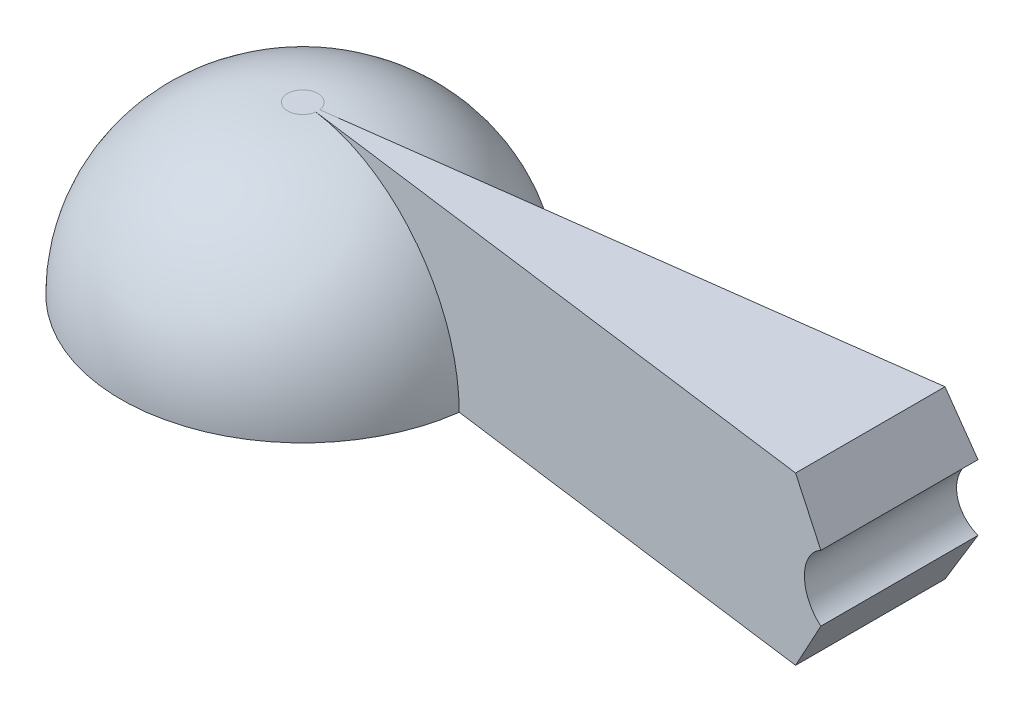
from build123d import *

# Parameters (mm, degrees)
REVOLVE2_ANGLE           = 7.5
REVOLVE2_OTHER_WAY_ANGLE = 7.5
CUT_EXTRUDE1_DEPTH       = 16.24
CUT_EXTRUDE1_DEPTH_BACK  = 16.24


with BuildPart() as part:
    # Sketch1 → Revolve1 (revolve)
    with BuildSketch(Plane.XY):
        with BuildLine():
            Line((0, 12.7), (-1.27, 12.7))
            Line((-1.27, 12.7), (-1.27, 13.97))
            Line((-1.27, 13.97), (0, 13.97))
            ThreePointArc((0, 13.97), (9.878281733, 9.878281733), (13.97, 0))
            Line((13.97, 0), (12.7, 0))
            ThreePointArc((12.7, 0), (8.980256121, 8.980256121), (0, 12.7))
        make_face()
    revolve(axis=Axis((-1.27, 13.97, 0), (0, -1, 0)))

    # Sketch3 → Revolve2 (revolve)
    with BuildSketch(Plane.XY):
        with BuildLine():
            Line((0, 13.97), (50.8, 13.97))
            Line((50.8, 13.97), (50.8, 0))
            Line((50.8, 0), (13.97, 0))
            ThreePointArc((13.97, 0), (9.878281733, 9.878281733), (0, 13.97))
        make_face()
    revolve(axis=Axis((-1.27, 13.97, 0), (0, -1, 0)), revolution_arc=REVOLVE2_ANGLE)

    # Sketch3 → Revolve2 other way (revolve)
    with BuildSketch(Plane.XY):
        with BuildLine():
            Line((0, 13.97), (50.8, 13.97))
            Line((50.8, 13.97), (50.8, 0))
            Line((50.8, 0), (13.97, 0))
            ThreePointArc((13.97, 0), (9.878281733, 9.878281733), (0, 13.97))
        make_face()
    revolve(axis=Axis((-1.27, 13.97, 0), (0, 1, 0)), revolution_arc=REVOLVE2_OTHER_WAY_ANGLE)

    # Sketch4 → Cut-Extrude1 (cut, two sides)
    with BuildSketch(Plane.XY) as cut_extrude1_sk:
        with BuildLine():
            Line((50.354533932, 13.97), (57.446880617, 13.97))
            Line((57.446880617, 13.97), (57.446880617, -0.511564319))
            Line((57.446880617, -0.511564319), (50.354533932, 0))
            Line((50.354533932, 0), (46.321742301, 0))
            Line((46.321742301, 0), (48.767033932, 4.235369343))
            ThreePointArc((48.767033932, 4.235369343), (47.179533932, 6.985), (48.767033932, 9.734630657))
            Line((48.767033932, 9.734630657), (46.321742301, 13.97))
            Line((46.321742301, 13.97), (50.354533932, 13.97))
        make_face()
    extrude(amount=CUT_EXTRUDE1_DEPTH, mode=Mode.SUBTRACT)
    extrude(cut_extrude1_sk.sketch, amount=-CUT_EXTRUDE1_DEPTH_BACK, mode=Mode.SUBTRACT)


solid = part.part
